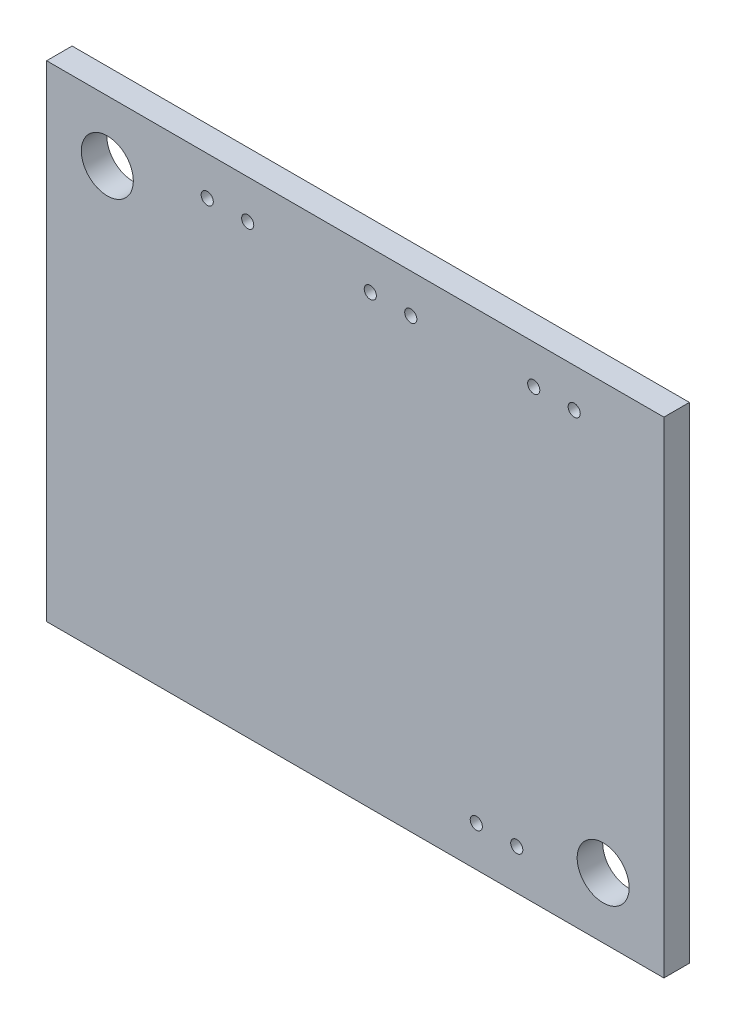
from build123d import *

# Parameters (mm, degrees)
SKETCH1_W                 = 38.735
SKETCH1_H                 = 30.48
BOSS_EXTRUDE1_DEPTH       = 0.8
F_4_CLEARANCE_HOLE1_D     = 3.2639
F_4_CLEARANCE_HOLE1_DEPTH = 10.922
F_4_CLEARANCE_HOLE1_TIP   = 0.980574487
SKETCH6_R                 = 0.381
CUT_EXTRUDE1_DEPTH        = 2.6


with BuildPart() as part:
    # Sketch1 → Boss-Extrude1 (new body, symmetric)
    with BuildSketch(Plane.XY):
        Rectangle(SKETCH1_W, SKETCH1_H)
    extrude(amount=BOSS_EXTRUDE1_DEPTH, both=True)

    # #4 Clearance Hole1
    with Locations(Plane.XY.offset(0.8)):
        with Locations((-15.5575, 11.43), (15.5575, -11.43)):
            Hole(F_4_CLEARANCE_HOLE1_D / 2, depth=F_4_CLEARANCE_HOLE1_DEPTH)
            with Locations((0, 0, -(F_4_CLEARANCE_HOLE1_DEPTH + F_4_CLEARANCE_HOLE1_TIP / 2))):  # 118° drill point
                Cone(0, F_4_CLEARANCE_HOLE1_D / 2, F_4_CLEARANCE_HOLE1_TIP, mode=Mode.SUBTRACT)

    # Sketch6 → Cut-Extrude1 (cut, through all)
    with BuildSketch(Plane.XY.offset(0.8)):
        with Locations((-9.289404292, 12.804978229)):
            Circle(SKETCH6_R)
        with Locations((-6.749404292, 12.804978229)):
            Circle(SKETCH6_R)
        with Locations((0.943821165, 12.804978229)):
            Circle(SKETCH6_R)
        with Locations((3.483821165, 12.804978229)):
            Circle(SKETCH6_R)
        with Locations((11.19802304, 12.804978229)):
            Circle(SKETCH6_R)
        with Locations((13.73802304, 12.804978229)):
            Circle(SKETCH6_R)
        with Locations((7.59553263, -12.709329553)):
            Circle(SKETCH6_R)
        with Locations((10.13553263, -12.709329553)):
            Circle(SKETCH6_R)
    extrude(amount=-CUT_EXTRUDE1_DEPTH, mode=Mode.SUBTRACT)


solid = part.part
